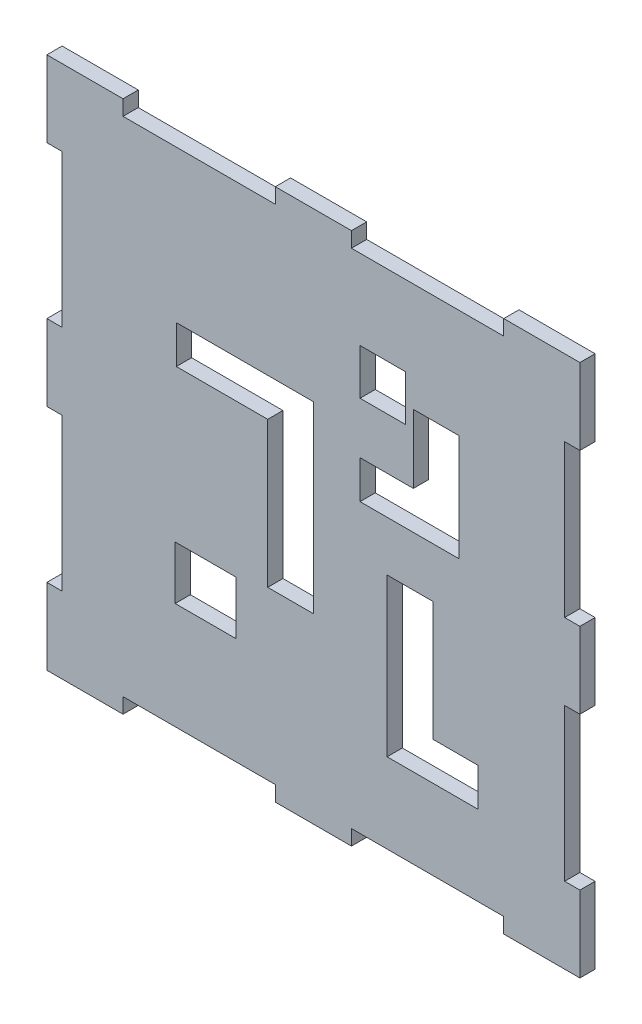
from build123d import *

# Parameters (mm, degrees)
SKETCH1_W           = 70
SKETCH1_H           = 70
BOSS_EXTRUDE1_DEPTH = 2
SKETCH2_W           = 2
SKETCH2_H           = 20
SKETCH2_W_2         = 20
SKETCH2_H_2         = 2
CUT_EXTRUDE1_DEPTH  = 2
SKETCH3_W           = 6
SKETCH3_H           = 14
SKETCH3_W_2         = 7
SKETCH3_H_2         = 5
SKETCH3_H_3         = 6
SKETCH3_H_4         = 11
SKETCH3_H_5         = 9.678877381
SKETCH3_W_3         = 5.911764375
SKETCH3_W_4         = 8
SKETCH3_H_6         = 7
SKETCH3_H_7         = 11.067115318
SKETCH3_H_8         = 13.044819002
SKETCH3_W_5         = 12
CUT_EXTRUDE2_DEPTH  = 10


with BuildPart() as part:
    # Sketch1 → Boss-Extrude1 (new body)
    with BuildSketch(Plane.XY):
        Rectangle(SKETCH1_W, SKETCH1_H)
    extrude(amount=-BOSS_EXTRUDE1_DEPTH)

    # Sketch2 → Cut-Extrude1 (cut)
    with BuildSketch(Plane.XY):
        with Locations((-34, 15)):
            Rectangle(SKETCH2_W, SKETCH2_H)
        with Locations((-34, -15)):
            Rectangle(SKETCH2_W, SKETCH2_H)
        with Locations((-15, -34)):
            Rectangle(SKETCH2_W_2, SKETCH2_H_2)
        with Locations((15, -34)):
            Rectangle(SKETCH2_W_2, SKETCH2_H_2)
        with Locations((34, -15)):
            Rectangle(SKETCH2_W, SKETCH2_H)
        with Locations((34, 15)):
            Rectangle(SKETCH2_W, SKETCH2_H)
        with Locations((15, 34)):
            Rectangle(SKETCH2_W_2, SKETCH2_H_2)
        with Locations((-15, 34)):
            Rectangle(SKETCH2_W_2, SKETCH2_H_2)
    extrude(amount=-CUT_EXTRUDE1_DEPTH, mode=Mode.SUBTRACT)

    # Sketch3 → Cut-Extrude2 (cut)
    with BuildSketch(Plane.XY):
        with Locations((16.127037524, 11.743568931)):
            Rectangle(SKETCH3_W, SKETCH3_H)
        with Locations((9.627037524, 7.243568931)):
            Rectangle(SKETCH3_W_2, SKETCH3_H_2)
        with Locations((9.127037524, 19.5)):
            Rectangle(SKETCH3_W, SKETCH3_H_3)
        with Locations((12.681095539, -7.321122619)):
            Rectangle(SKETCH3_W, SKETCH3_H_4)
        with Locations((12.681095539, -17.66056131)):
            Rectangle(SKETCH3_W, SKETCH3_H_5)
        with Locations((18.636977726, -20)):
            Rectangle(SKETCH3_W_3, SKETCH3_H_2)
        with Locations((-14.154511362, -15.485830005)):
            Rectangle(SKETCH3_W_4, SKETCH3_H_6)
        with Locations((-3, -5.533557659)):
            Rectangle(SKETCH3_W, SKETCH3_H_7)
        with Locations((-3, 6.522409501)):
            Rectangle(SKETCH3_W, SKETCH3_H_8)
        with Locations((-12, 10.544819002)):
            Rectangle(SKETCH3_W_5, SKETCH3_H_2)
    extrude(amount=-CUT_EXTRUDE2_DEPTH, mode=Mode.SUBTRACT)


solid = part.part
